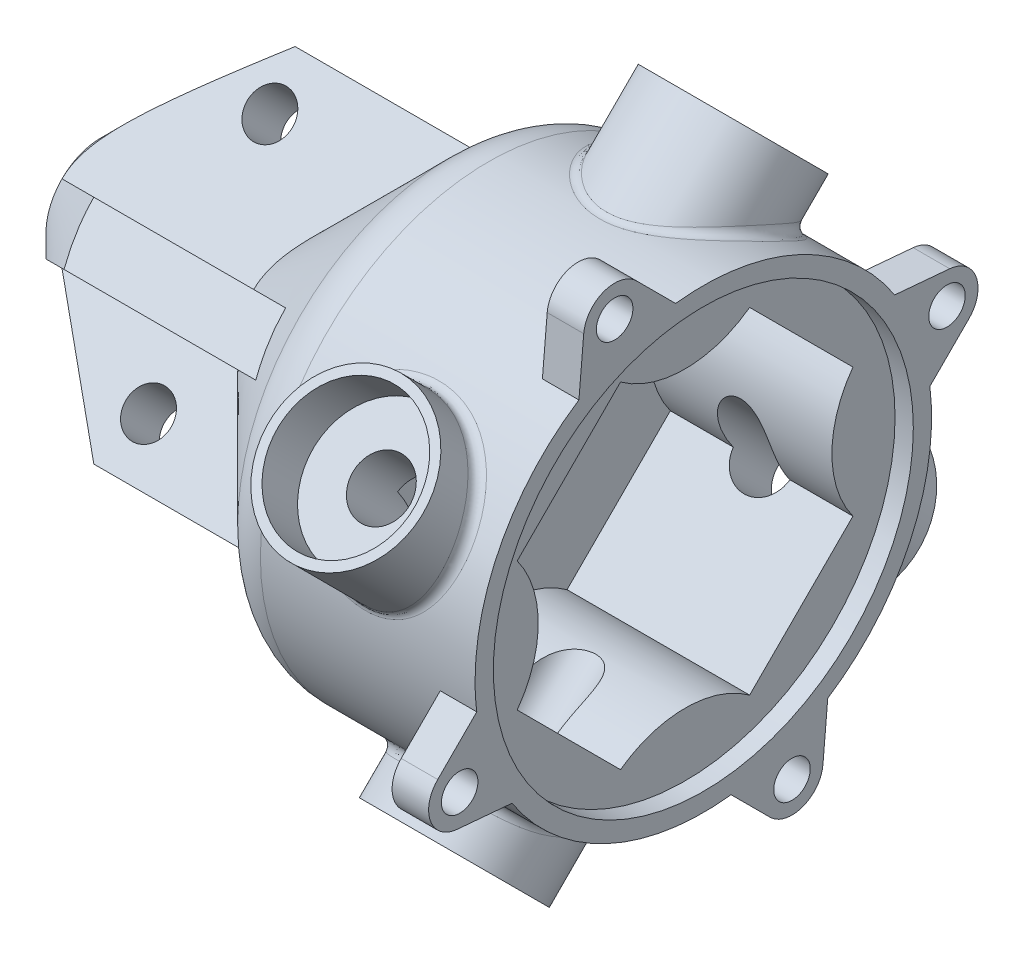
from build123d import *

# Parameters (mm, degrees)
SKETCH2_R           = 31.75
BOSS_EXTRUDE1_DEPTH = 27.94
SKETCH3_R           = 10.795
BOSS_EXTRUDE2_DEPTH = 38.1
SKETCH4_R           = 3.96875
CUT_EXTRUDE1_DEPTH  = 25.4
SKETCH9_R           = 9.525
CUT_EXTRUDE6_DEPTH  = 6.985
CIRPATTERN14_COUNT  = 4
CUT_EXTRUDE7_DEPTH  = 66.790535728
SKETCH7_R           = 6.985
BOSS_EXTRUDE3_DEPTH = 7.62
SKETCH19_W          = 7.62
SKETCH19_H          = 22.733
BOSS_EXTRUDE8_DEPTH = 50.8
CIRPATTERN19_COUNT  = 4
SKETCH8_R           = 3.175
CUT_EXTRUDE4_DEPTH  = 82.672060007
CIRPATTERN16_COUNT  = 4
FILLET4_R           = 7.62
FILLET5_R           = 1.27
BOSS_EXTRUDE4_START = -5.08
SKETCH14_R          = 2.54
BOSS_EXTRUDE4_DEPTH = 5.08
CIRPATTERN15_COUNT  = 4
SKETCH15_R          = 29.21
CUT_EXTRUDE8_DEPTH  = 2.54


with BuildPart() as part:
    # Sketch2 → Boss-Extrude1 (new body)
    with BuildSketch(Plane(origin=(0, 0, 0), x_dir=(0, 0, -1), z_dir=(1, 0, 0))):
        Circle(SKETCH2_R)
    extrude(amount=BOSS_EXTRUDE1_DEPTH)

    # Sketch3 → Boss-Extrude2 (add)
    with BuildSketch(Plane(origin=(0, 0, 0), x_dir=(1, 0, 0), z_dir=(0, 0.7071067811865488, -0.7071067811865464))):
        with Locations((12.7, 10.668)):
            Circle(SKETCH3_R)
    boss_extrude2 = extrude(amount=-BOSS_EXTRUDE2_DEPTH)

    # Sketch4 → Cut-Extrude1 (cut)
    with BuildSketch(Plane(origin=(0, -26.940768363, 26.940768363), x_dir=(-1, 0, 0), z_dir=(0, -0.7071067811865489, 0.7071067811865462))):
        with Locations((-12.7, 10.668)):
            Circle(SKETCH4_R)
    cut_extrude1 = extrude(amount=-CUT_EXTRUDE1_DEPTH, mode=Mode.SUBTRACT)

    # Sketch9 → Cut-Extrude6 (cut)
    with BuildSketch(Plane(origin=(0, -26.940768363, 26.940768363), x_dir=(-1, 0, 0), z_dir=(0, -0.7071067811865489, 0.7071067811865462))):
        with Locations((-12.7, 10.668)):
            Circle(SKETCH9_R)
    cut_extrude6 = extrude(amount=-CUT_EXTRUDE6_DEPTH, mode=Mode.SUBTRACT)

    # CirPattern14: Boss-Extrude2, Cut-Extrude1, Cut-Extrude6 ×4 about axis
    cirpattern14_axis = Axis((0, 0, 0), (1, 0, 0))
    add([boss_extrude2.rotate(cirpattern14_axis, i * 360 / CIRPATTERN14_COUNT) for i in range(1, CIRPATTERN14_COUNT)])
    add([cut_extrude1.rotate(cirpattern14_axis, i * 360 / CIRPATTERN14_COUNT) for i in range(1, CIRPATTERN14_COUNT)], mode=Mode.SUBTRACT)
    add([cut_extrude6.rotate(cirpattern14_axis, i * 360 / CIRPATTERN14_COUNT) for i in range(1, CIRPATTERN14_COUNT)], mode=Mode.SUBTRACT)

    # Sketch11 → Cut-Extrude7 (cut, through all)
    with BuildSketch(Plane(origin=(0, 0, 0), x_dir=(0, 0, -1), z_dir=(1, 0, 0))):
        with BuildLine():
            Line((-23.348665915, 8.980256121), (-8.980256121, 23.348665915))
            ThreePointArc((-8.980256121, 23.348665915), (0, 20.421772753), (8.980256121, 23.348665915))
            Line((8.980256121, 23.348665915), (23.348665915, 8.980256121))
            ThreePointArc((23.348665915, 8.980256121), (20.421772753, 0), (23.348665915, -8.980256121))
            Line((23.348665915, -8.980256121), (8.980256121, -23.348665915))
            ThreePointArc((8.980256121, -23.348665915), (0, -20.421772753), (-8.980256121, -23.348665915))
            Line((-8.980256121, -23.348665915), (-23.348665915, -8.980256121))
            ThreePointArc((-23.348665915, -8.980256121), (-20.421772753, 0), (-23.348665915, 8.980256121))
        make_face()
    extrude(amount=CUT_EXTRUDE7_DEPTH, mode=Mode.SUBTRACT)

    # Sketch6 → Revolve1 (revolve)
    with BuildSketch(Plane.XY):
        Polygon((-5.08, 0), (-5.08, 2.5), (0, 2.5), (0, 31.75), (-5.08, 31.75), (-36.83, 0), align=None)
    revolve(axis=Axis((0, 0, 0), (-1, 0, 0)))



with BuildPart() as body_2:
    # Sketch7 → Boss-Extrude3 (new body)
    with BuildSketch(Plane(origin=(0, 0, 0), x_dir=(1, 0, 0), z_dir=(0, -0.7071067811865488, 0.7071067811865464))):
        with Locations((-38.1, -15.748)):
            Circle(SKETCH7_R)
    extrude(amount=-BOSS_EXTRUDE3_DEPTH)


with BuildPart() as part_1:
    add(part.part)

    add(body_2.part)  # Boss-Extrude8 merges body 2
    # Sketch19 → Boss-Extrude8 (add)
    with BuildSketch(Plane(origin=(-5.08, -3.592102448, 3.592102448), x_dir=(0, -0.7071067811865488, 0.7071067811865464), z_dir=(-1, 0, 0))):
        with Locations((-8.89, -11.3665)):
            Rectangle(SKETCH19_W, SKETCH19_H)
    boss_extrude8 = extrude(amount=BOSS_EXTRUDE8_DEPTH)

    # CirPattern19: Boss-Extrude8 ×4 about axis
    cirpattern19_axis = Axis((27.94, 0, 0), (-1, 0, 0))
    for i in range(1, CIRPATTERN19_COUNT):
        add(boss_extrude8.rotate(cirpattern19_axis, i * 360 / CIRPATTERN19_COUNT))

    # Sketch8 → Cut-Extrude4 (cut, through all)
    with BuildSketch(Plane(origin=(0, 0, 0), x_dir=(1, 0, 0), z_dir=(0, 0.7071067811865488, -0.7071067811865464))):
        with Locations((-38.1, 15.748)):
            Circle(SKETCH8_R)
    cut_extrude4 = extrude(amount=CUT_EXTRUDE4_DEPTH, mode=Mode.SUBTRACT)

    # CirPattern16: Cut-Extrude4 ×4 about axis
    cirpattern16_axis = Axis((-5.08, 0, 0), (-1, 0, 0))
    for i in range(1, CIRPATTERN16_COUNT):
        add(cut_extrude4.rotate(cirpattern16_axis, i * 360 / CIRPATTERN16_COUNT), mode=Mode.SUBTRACT)

    # Sketch20 → Cut-Revolve1 (revolve, cut)
    with BuildSketch(Plane(origin=(0, 0, 0), x_dir=(1, 0, 0), z_dir=(0, -0.7071067811865487, 0.7071067811865465))):
        Polygon((-31.75, -31.75), (-55.88, -7.62), (-55.88, -31.75), align=None)
    revolve(axis=Axis((0, 0, 0), (-1, 0, 0)), mode=Mode.SUBTRACT)

    # Fillet4
    fillet4_edges = [part_1.edges().sort_by_distance(p)[0] for p in [
        (-5.08, -31.75, 0),
    ]]
    fillet(fillet4_edges, radius=FILLET4_R)

    # Fillet5
    fillet5_edges = [part_1.edges().sort_by_distance(p)[0] for p in [
        (1.958063455, 12.560971624, 29.159638056),
        (1.958063455, -29.159638056, 12.560971624),
        (1.958063455, 29.159638056, -12.560971624),
        (1.958063455, -12.560971624, -29.159638056),
    ]]
    fillet(fillet5_edges, radius=FILLET5_R)

    # Sketch14 → Boss-Extrude4 (add)
    with BuildSketch(Plane(origin=(27.94, 0, 0), x_dir=(0, 0, -1), z_dir=(1, 0, 0)).offset(BOSS_EXTRUDE4_START)):
        with BuildLine():
            Line((-17.306917068, 26.618285475), (-16.637551236, 34.269171944))
            ThreePointArc((-16.637551236, 34.269171944), (-13.812825508, 37.950426183), (-9.282695448, 36.946120528))
            Line((-9.282695448, 36.946120528), (-3.852036447, 31.515461526))
            ThreePointArc((-3.852036447, 31.515461526), (-10.859139551, 29.83524071), (-17.306917068, 26.618285475))
        make_face()
        with Locations((-12.335982529, 33.892833447)):
            Circle(SKETCH14_R, mode=Mode.SUBTRACT)
    boss_extrude4 = extrude(amount=BOSS_EXTRUDE4_DEPTH)

    # CirPattern15: Boss-Extrude4 ×4 about axis
    cirpattern15_axis = Axis((27.94, 0, 0), (-1, 0, 0))
    for i in range(1, CIRPATTERN15_COUNT):
        add(boss_extrude4.rotate(cirpattern15_axis, i * 360 / CIRPATTERN15_COUNT))

    # Sketch15 → Cut-Extrude8 (cut)
    with BuildSketch(Plane(origin=(27.94, 0, 0), x_dir=(0, 0, -1), z_dir=(1, 0, 0))):
        Circle(SKETCH15_R)
    extrude(amount=-CUT_EXTRUDE8_DEPTH, mode=Mode.SUBTRACT)


solid = part_1.part
